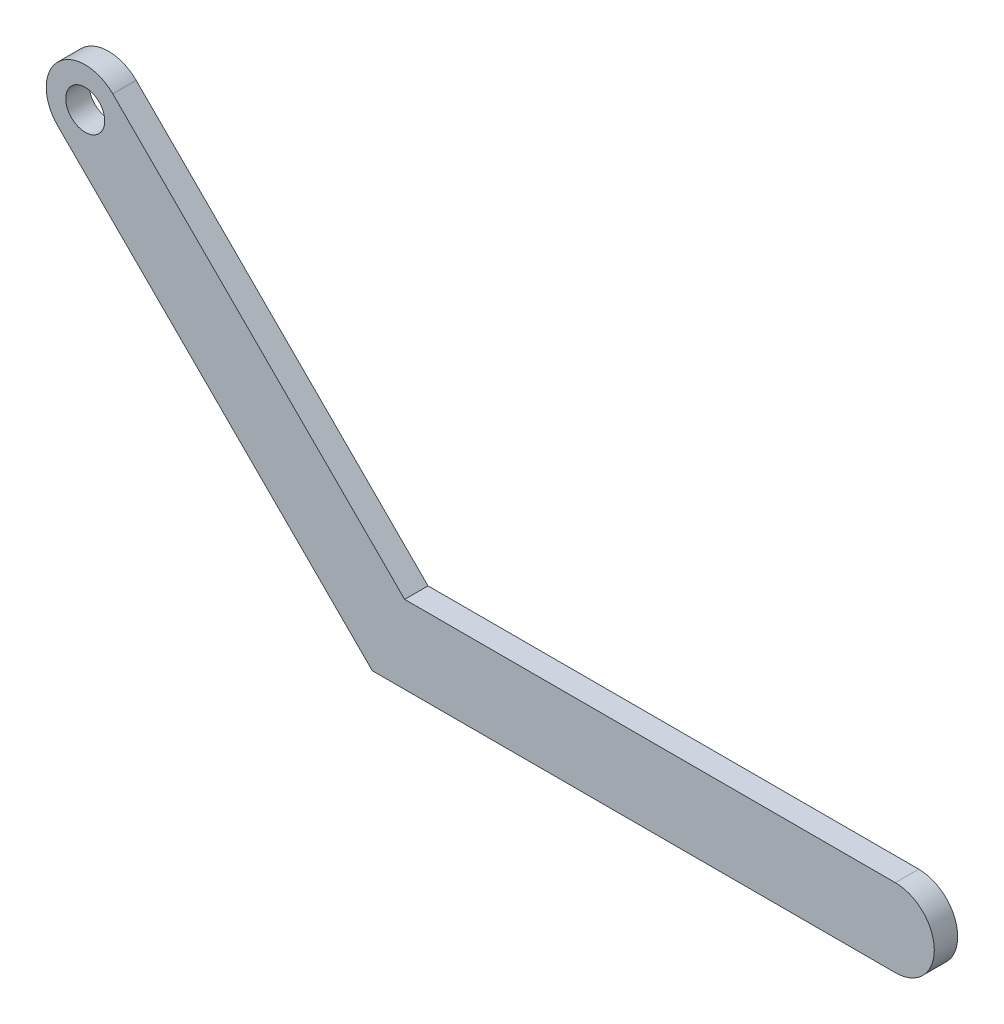
from build123d import *

# Parameters (mm, degrees)
BOSS_EXTRUDE1_DEPTH = 3
SKETCH3_R           = 2.5
CUT_EXTRUDE1_DEPTH  = 11


with BuildPart() as part:
    # Sketch2 → Boss-Extrude1 (new body)
    with BuildSketch(Plane.XY):
        with BuildLine():
            Line((2.071067812, 5), (65, 5))
            ThreePointArc((65, 5), (70, 0), (65, -5))
            Line((65, -5), (-2.071067812, -5))
            Line((-2.071067812, -5), (-42.426406871, 35.355339059))
            ThreePointArc((-42.426406871, 35.355339059), (-42.426406871, 42.426406871), (-35.355339059, 42.426406871))
            Line((-35.355339059, 42.426406871), (2.071067812, 5))
        make_face()
    extrude(amount=BOSS_EXTRUDE1_DEPTH)

    # Sketch3 → Cut-Extrude1 (cut)
    with BuildSketch(Plane.XY.offset(3)):
        with Locations((-38.890872965, 38.890872965)):
            Circle(SKETCH3_R)
    extrude(amount=-CUT_EXTRUDE1_DEPTH, mode=Mode.SUBTRACT)


solid = part.part
